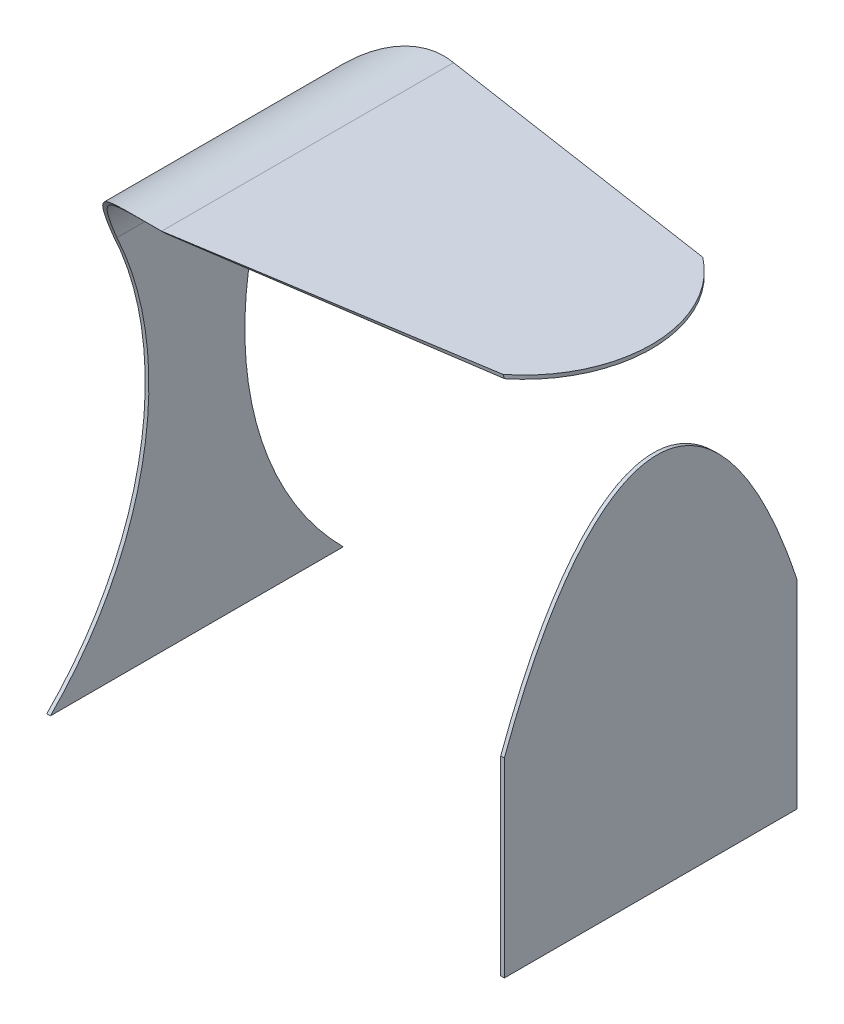
from build123d import *

# Parameters (mm, degrees)
EXTRUDE_THIN3_DEPTH = 160
SKETCH2_W           = 187.5
SKETCH2_H           = 160
CUT_EXTRUDE1_DEPTH  = 50
SKETCH3_W           = 41.338568599
SKETCH3_H           = 174.810809694
CUT_EXTRUDE2_DEPTH  = 50
CUT_EXTRUDE3_DEPTH  = 50
CUT_EXTRUDE4_DEPTH  = 76
CUT_EXTRUDE5_DEPTH  = 76
CUT_EXTRUDE6_DEPTH  = 76
SKETCH15_W          = 101.681727428
SKETCH15_H          = 2
CUT_EXTRUDE7_DEPTH  = 28


with BuildPart() as part:
    # Sketch1 → Extrude-Thin3 (new body)
    with BuildSketch(Plane.XY):
        with BuildLine():
            Line((0, -108.136343176), (0, -58.136343176))
            Line((0, -58.136343176), (0, 0))
            Line((0, 0), (0, 100))
            ThreePointArc((0, 100), (20.62169433, 138.603173517), (62.5, 151.317999385))
            Line((62.5, 151.317999385), (187.5, 151.317999385))
            ThreePointArc((187.5, 151.317999385), (229.37830567, 138.603173517), (250, 100))
            Line((250, 100), (250, 0))
            Line((250, 0), (250, -58.136343176))
            Line((250, -58.136343176), (250, -108.136343176))
            Line((250, -108.136343176), (248, -108.136343176))
            Line((248, -108.136343176), (248, -58.136343176))
            Line((248, -58.136343176), (248, 0))
            Line((248, 0), (248, 99.901116926))
            ThreePointArc((248, 99.901116926), (228.034012999, 137.119039063), (187.598883074, 149.317999385))
            Line((187.598883074, 149.317999385), (62.401116926, 149.317999385))
            ThreePointArc((62.401116926, 149.317999385), (21.965987001, 137.119039063), (2, 99.901116926))
            Line((2, 99.901116926), (2, 0))
            Line((2, 0), (2, -58.136343176))
            Line((2, -58.136343176), (2, -108.136343176))
            Line((2, -108.136343176), (0, -108.136343176))
        make_face()
    extrude(amount=EXTRUDE_THIN3_DEPTH)

    # Sketch2 → Cut-Extrude1 (cut)
    with BuildSketch(Plane(origin=(0, 151.317999385, 0), x_dir=(1, 0, 0), z_dir=(0, 1, 0))):
        with Locations((156.25, -80)):
            Rectangle(SKETCH2_W, SKETCH2_H)
    extrude(amount=-CUT_EXTRUDE1_DEPTH, mode=Mode.SUBTRACT)


with BuildPart() as cut_extrude1_piece_1:
    # of the separate pieces the step leaves, piece 1, a body of its own (cut_extrude1_pieces)
    add(part.part.solids().sort_by_distance((0, -108.136343176, 0))[0])

    # Sketch4 → Cut-Extrude3 (cut)
    with BuildSketch(Plane.ZY):
        with BuildLine():
            Line((0, 100), (0, -108.136343176))
            ThreePointArc((0, -108.136343176), (43.106448083, -4.068171588), (0, 100))
        make_face()
        with BuildLine():
            Line((160, 100), (160, -108.136343176))
            ThreePointArc((160, -108.136343176), (116.893551917, -4.068171588), (160, 100))
        make_face()
    extrude(amount=-CUT_EXTRUDE3_DEPTH, mode=Mode.SUBTRACT)

    # Sketch10 → Cut-Extrude4 (cut)
    with BuildSketch(Plane.ZY):
        with BuildLine():
            Line((160, 151.591982567), (160, -108.136343176))
            ThreePointArc((160, -108.136343176), (106.208502472, 21.727819696), (160, 151.591982567))
        make_face()
    extrude(amount=-CUT_EXTRUDE4_DEPTH, mode=Mode.SUBTRACT)

    # Sketch11 → Cut-Extrude5 (cut)
    with BuildSketch(Plane.ZY):
        with BuildLine():
            Line((0, 151.591982567), (0, -108.136343176))
            ThreePointArc((0, -108.136343176), (53.791497528, 21.727819696), (0, 151.591982567))
        make_face()
    extrude(amount=-CUT_EXTRUDE5_DEPTH, mode=Mode.SUBTRACT)

    # Sketch15 → section 1 of loft2
    with BuildSketch(Plane(origin=(250, 0, 0), x_dir=(0, 0, -1), z_dir=(1, 0, 0)), mode=Mode.PRIVATE) as loft2_s1:
        with Locations((-79.189925073, 150.317999385)):
            Rectangle(SKETCH15_W, SKETCH15_H)
    # loft from a face of the part (loft2)
    loft([cut_extrude1_piece_1.faces().sort_by_distance((62.5, 150.322150962, 80))[0], loft2_s1.sketch])

    # Sketch16 → Cut-Extrude7 (cut)
    with BuildSketch(Plane(origin=(0, 151.317999385, 0), x_dir=(1, 0, 0), z_dir=(0, 1, 0))):
        with BuildLine():
            Line((156.25, -14.311233858), (176.822030282, 28.432325683))
            Line((176.822030282, 28.432325683), (259.553291399, -32.590672084))
            Line((259.553291399, -32.590672084), (263.183560197, -157.384709674))
            Line((263.183560197, -157.384709674), (159.971927258, -160.387144549))
            Line((159.971927258, -160.387144549), (156.25, -144.878691215))
            ThreePointArc((156.25, -144.878691215), (250, -79.594962536), (156.25, -14.311233858))
        make_face()
    extrude(amount=-CUT_EXTRUDE7_DEPTH, mode=Mode.SUBTRACT)


with BuildPart() as cut_extrude1_piece_2:
    # of the separate pieces the step leaves, piece 2, a body of its own (cut_extrude1_pieces)
    add(part.part.solids().sort_by_distance((249.855066879, 101.317999385, 160))[0])

    # Sketch12 → Cut-Extrude6 (cut)
    with BuildSketch(Plane(origin=(250, 0, 0), x_dir=(0, 0, -1), z_dir=(1, 0, 0))):
        with BuildLine():
            Line((-160, -4.068171588), (-160, 100))
            Line((-160, 100), (-160, 129.751357578))
            Line((-160, 129.751357578), (0, 129.751357578))
            Line((0, 129.751357578), (0, 0))
            add(Edge.make_bspline(
                [(-160, -4.068171588), (-74.35058709, 228.559103464), (0, 0)],
                knots=[0, 0, 0, 1, 1, 1], degree=2, weights=[1, 0.761512218, 1]))
        make_face()
    extrude(amount=-CUT_EXTRUDE6_DEPTH, mode=Mode.SUBTRACT)


with BuildPart() as cut_extrude1_piece_3:
    # of the separate pieces the step leaves, piece 3, a body of its own (cut_extrude1_pieces)
    add(part.part.solids().sort_by_distance((198.682000615, 151.317999385, 160))[0])

    # Sketch3 → Cut-Extrude2 (cut)
    with BuildSketch(Plane.XZ.offset(-151.317999385)):
        with Locations((192.9519608, 76.21738588)):
            Rectangle(SKETCH3_W, SKETCH3_H)
    extrude(amount=-CUT_EXTRUDE2_DEPTH, mode=Mode.SUBTRACT)


solid = Compound([cut_extrude1_piece_1.part, cut_extrude1_piece_2.part])
